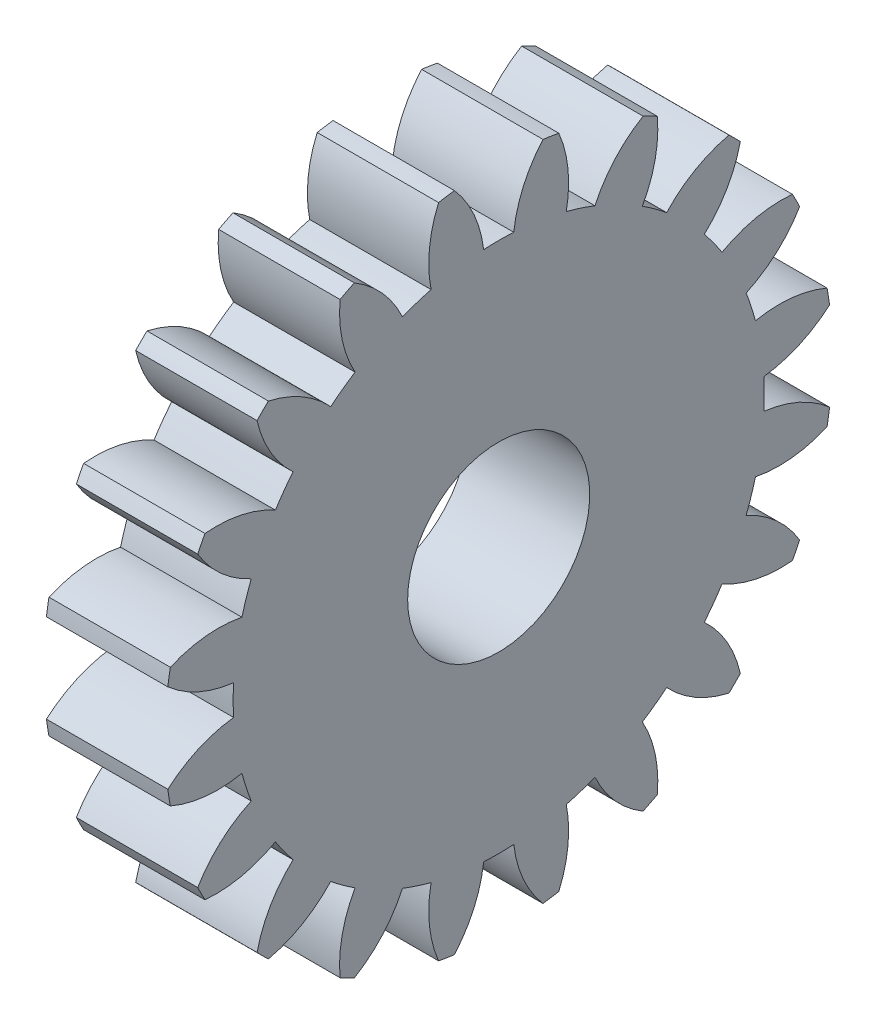
from build123d import *

# Parameters (mm, degrees)
BASPROSKE_W     = 6
BASPROSKE_H     = 16.5
TOOTHCUT_DEPTH  = 25.093567606
TEETHCUTS_COUNT = 20
TEETHCUTS_ANGLE = 342
BORSKE_R        = 4.5
BORE_DEPTH      = 50.0000508


with BuildPart() as part:
    # BasProSke → Base-Revolve (revolve)
    with BuildSketch(Plane(origin=(0, 0, 0), x_dir=(1, 0, 0), z_dir=(0, 1, 0)), mode=Mode.PRIVATE) as base_revolve_sk:
        with Locations((3, 8.25)):
            Rectangle(BASPROSKE_W, BASPROSKE_H)
    revolve(base_revolve_sk.sketch.rotate(Axis((-10, 0, 0), (1, 0, 0)), 180), axis=Axis((-10, 0, 0), (1, 0, 0)))

    # TooCutSke → ToothCut (cut, through all)
    with BuildSketch(Plane(origin=(0, 0, 0), x_dir=(0, 0, -1), z_dir=(1, 0, 0))):
        with BuildLine():
            ThreePointArc((0.74381438, 13.102904875), (0, 13.124), (-0.74381438, 13.102904875))
            ThreePointArc((-0.74381438, 13.102904875), (-1.226473103, 14.852072512), (-2.209965745, 16.376962373))
            ThreePointArc((-2.209965745, 16.376962373), (0, 16.5254), (2.209965745, 16.376962373))
            ThreePointArc((2.209965745, 16.376962373), (1.226473103, 14.852072512), (0.74381438, 13.102904875))
        make_face()
    toothcut = extrude(amount=TOOTHCUT_DEPTH, mode=Mode.SUBTRACT)

    # TeethCuts: ToothCut ×20 about axis
    teethcuts_axis = Axis((-10, 0, 0), (1, 0, 0))
    for i in range(1, TEETHCUTS_COUNT):
        add(toothcut.rotate(teethcuts_axis, i * TEETHCUTS_ANGLE / (TEETHCUTS_COUNT - 1)), mode=Mode.SUBTRACT)

    # BorSke → Bore (cut, symmetric)
    with BuildSketch(Plane(origin=(0, 0, 0), x_dir=(0, 0, -1), z_dir=(1, 0, 0))):
        with Locations(Location((0, 0, 0), (0, 0, 180))):
            Circle(BORSKE_R)
    extrude(amount=BORE_DEPTH, both=True, mode=Mode.SUBTRACT)


solid = part.part
